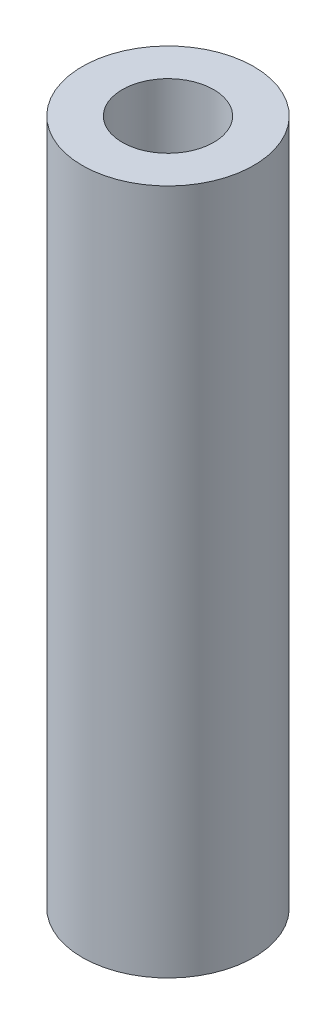
from build123d import *

# Parameters (mm, degrees)
CROQUIS1_W = 7
CROQUIS1_H = 120


with BuildPart() as part:
    # Croquis1 → Revolución1 (revolve)
    with BuildSketch(Plane(origin=(0, 0, 0), x_dir=(0, 0, -1), z_dir=(1, 0, 0))):
        with Locations((11.5, 60)):
            Rectangle(CROQUIS1_W, CROQUIS1_H)
    revolve(axis=Axis((0, 0, 0), (0, 1, 0)))


solid = part.part
